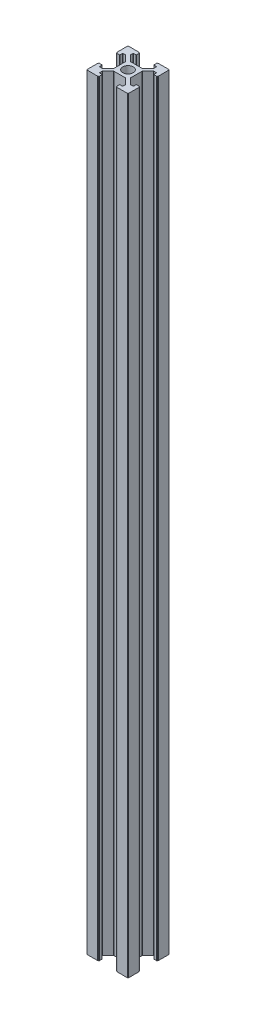
from build123d import *

# Parameters (mm, degrees)
SKETCH1_R           = 2.5
BOSS_EXTRUDE1_DEPTH = 370


with BuildPart() as part:
    # Sketch1 → Boss-Extrude1 (new body)
    with BuildSketch(Plane(origin=(0, 0, 0), x_dir=(1, 0, 0), z_dir=(0, 1, 0))):
        with BuildLine():
            Line((-10, 4.65), (-9.8, 4.65))
            Line((-9.8, 4.65), (-9.8, 4.4))
            ThreePointArc((-9.8, 4.4), (-9.741421356, 4.258578644), (-9.6, 4.2))
            Line((-9.6, 4.2), (-8.4, 4.2))
            ThreePointArc((-8.4, 4.2), (-8.258578644, 4.258578644), (-8.2, 4.4))
            Line((-8.2, 4.4), (-8.2, 5.45))
            ThreePointArc((-8.2, 5.45), (-8.141421356, 5.591421356), (-8, 5.65))
            Line((-8, 5.65), (-6.832842712, 5.65))
            ThreePointArc((-6.832842712, 5.65), (-6.756306026, 5.634775907), (-6.691421356, 5.591421356))
            Line((-6.691421356, 5.591421356), (-4.058578644, 2.958578644))
            ThreePointArc((-4.058578644, 2.958578644), (-4.015224093, 2.893693974), (-4, 2.817157288))
            Line((-4, 2.817157288), (-4, -2.817157288))
            ThreePointArc((-4, -2.817157288), (-4.015224093, -2.893693974), (-4.058578644, -2.958578644))
            Line((-4.058578644, -2.958578644), (-6.691421356, -5.591421356))
            ThreePointArc((-6.691421356, -5.591421356), (-6.756306026, -5.634775907), (-6.832842712, -5.65))
            Line((-6.832842712, -5.65), (-8, -5.65))
            ThreePointArc((-8, -5.65), (-8.141421356, -5.591421356), (-8.2, -5.45))
            Line((-8.2, -5.45), (-8.2, -4.4))
            ThreePointArc((-8.2, -4.4), (-8.258578644, -4.258578644), (-8.4, -4.2))
            Line((-8.4, -4.2), (-9.6, -4.2))
            ThreePointArc((-9.6, -4.2), (-9.741421356, -4.258578644), (-9.8, -4.4))
            Line((-9.8, -4.4), (-9.8, -4.65))
            Line((-9.8, -4.65), (-10, -4.65))
            Line((-10, -4.65), (-10, -9.8))
            ThreePointArc((-10, -9.8), (-9.941421356, -9.941421356), (-9.8, -10))
            Line((-9.8, -10), (-4.65, -10))
            Line((-4.65, -10), (-4.65, -9.8))
            Line((-4.65, -9.8), (-4.4, -9.8))
            ThreePointArc((-4.4, -9.8), (-4.258578644, -9.741421356), (-4.2, -9.6))
            Line((-4.2, -9.6), (-4.2, -8.4))
            ThreePointArc((-4.2, -8.4), (-4.258578644, -8.258578644), (-4.4, -8.2))
            Line((-4.4, -8.2), (-5.45, -8.2))
            ThreePointArc((-5.45, -8.2), (-5.591421356, -8.141421356), (-5.65, -8))
            Line((-5.65, -8), (-5.65, -6.832842712))
            ThreePointArc((-5.65, -6.832842712), (-5.634775907, -6.756306026), (-5.591421356, -6.691421356))
            Line((-5.591421356, -6.691421356), (-2.958578644, -4.058578644))
            ThreePointArc((-2.958578644, -4.058578644), (-2.893693974, -4.015224093), (-2.817157288, -4))
            Line((-2.817157288, -4), (2.817157288, -4))
            ThreePointArc((2.817157288, -4), (2.893693974, -4.015224093), (2.958578644, -4.058578644))
            Line((2.958578644, -4.058578644), (5.591421356, -6.691421356))
            ThreePointArc((5.591421356, -6.691421356), (5.634775907, -6.756306026), (5.65, -6.832842712))
            Line((5.65, -6.832842712), (5.65, -8))
            ThreePointArc((5.65, -8), (5.591421356, -8.141421356), (5.45, -8.2))
            Line((5.45, -8.2), (4.4, -8.2))
            ThreePointArc((4.4, -8.2), (4.258578644, -8.258578644), (4.2, -8.4))
            Line((4.2, -8.4), (4.2, -9.6))
            ThreePointArc((4.2, -9.6), (4.258578644, -9.741421356), (4.4, -9.8))
            Line((4.4, -9.8), (4.65, -9.8))
            Line((4.65, -9.8), (4.65, -10))
            Line((4.65, -10), (9.8, -10))
            ThreePointArc((9.8, -10), (9.941421356, -9.941421356), (10, -9.8))
            Line((10, -9.8), (10, -4.65))
            Line((10, -4.65), (9.8, -4.65))
            Line((9.8, -4.65), (9.8, -4.4))
            ThreePointArc((9.8, -4.4), (9.741421356, -4.258578644), (9.6, -4.2))
            Line((9.6, -4.2), (8.4, -4.2))
            ThreePointArc((8.4, -4.2), (8.258578644, -4.258578644), (8.2, -4.4))
            Line((8.2, -4.4), (8.2, -5.45))
            ThreePointArc((8.2, -5.45), (8.141421356, -5.591421356), (8, -5.65))
            Line((8, -5.65), (6.832842712, -5.65))
            ThreePointArc((6.832842712, -5.65), (6.756306026, -5.634775907), (6.691421356, -5.591421356))
            Line((6.691421356, -5.591421356), (4.058578644, -2.958578644))
            ThreePointArc((4.058578644, -2.958578644), (4.015224093, -2.893693974), (4, -2.817157288))
            Line((4, -2.817157288), (4, 2.817157288))
            ThreePointArc((4, 2.817157288), (4.015224093, 2.893693974), (4.058578644, 2.958578644))
            Line((4.058578644, 2.958578644), (6.691421356, 5.591421356))
            ThreePointArc((6.691421356, 5.591421356), (6.756306026, 5.634775907), (6.832842712, 5.65))
            Line((6.832842712, 5.65), (8, 5.65))
            ThreePointArc((8, 5.65), (8.141421356, 5.591421356), (8.2, 5.45))
            Line((8.2, 5.45), (8.2, 4.4))
            ThreePointArc((8.2, 4.4), (8.258578644, 4.258578644), (8.4, 4.2))
            Line((8.4, 4.2), (9.6, 4.2))
            ThreePointArc((9.6, 4.2), (9.741421356, 4.258578644), (9.8, 4.4))
            Line((9.8, 4.4), (9.8, 4.65))
            Line((9.8, 4.65), (10, 4.65))
            Line((10, 4.65), (10, 9.8))
            ThreePointArc((10, 9.8), (9.941421356, 9.941421356), (9.8, 10))
            Line((9.8, 10), (4.65, 10))
            Line((4.65, 10), (4.65, 9.8))
            Line((4.65, 9.8), (4.4, 9.8))
            ThreePointArc((4.4, 9.8), (4.258578644, 9.741421356), (4.2, 9.6))
            Line((4.2, 9.6), (4.2, 8.4))
            ThreePointArc((4.2, 8.4), (4.258578644, 8.258578644), (4.4, 8.2))
            Line((4.4, 8.2), (5.45, 8.2))
            ThreePointArc((5.45, 8.2), (5.591421356, 8.141421356), (5.65, 8))
            Line((5.65, 8), (5.65, 6.832842712))
            ThreePointArc((5.65, 6.832842712), (5.634775907, 6.756306026), (5.591421356, 6.691421356))
            Line((5.591421356, 6.691421356), (2.958578644, 4.058578644))
            ThreePointArc((2.958578644, 4.058578644), (2.893693974, 4.015224093), (2.817157288, 4))
            Line((2.817157288, 4), (-2.817157288, 4))
            ThreePointArc((-2.817157288, 4), (-2.893693974, 4.015224093), (-2.958578644, 4.058578644))
            Line((-2.958578644, 4.058578644), (-5.591421356, 6.691421356))
            ThreePointArc((-5.591421356, 6.691421356), (-5.634775907, 6.756306026), (-5.65, 6.832842712))
            Line((-5.65, 6.832842712), (-5.65, 8))
            ThreePointArc((-5.65, 8), (-5.591421356, 8.141421356), (-5.45, 8.2))
            Line((-5.45, 8.2), (-4.4, 8.2))
            ThreePointArc((-4.4, 8.2), (-4.258578644, 8.258578644), (-4.2, 8.4))
            Line((-4.2, 8.4), (-4.2, 9.6))
            ThreePointArc((-4.2, 9.6), (-4.258578644, 9.741421356), (-4.4, 9.8))
            Line((-4.4, 9.8), (-4.65, 9.8))
            Line((-4.65, 9.8), (-4.65, 10))
            Line((-4.65, 10), (-9.8, 10))
            ThreePointArc((-9.8, 10), (-9.941421356, 9.941421356), (-10, 9.8))
            Line((-10, 9.8), (-10, 4.65))
        make_face()
        Circle(SKETCH1_R, mode=Mode.SUBTRACT)
    extrude(amount=BOSS_EXTRUDE1_DEPTH)


solid = part.part
